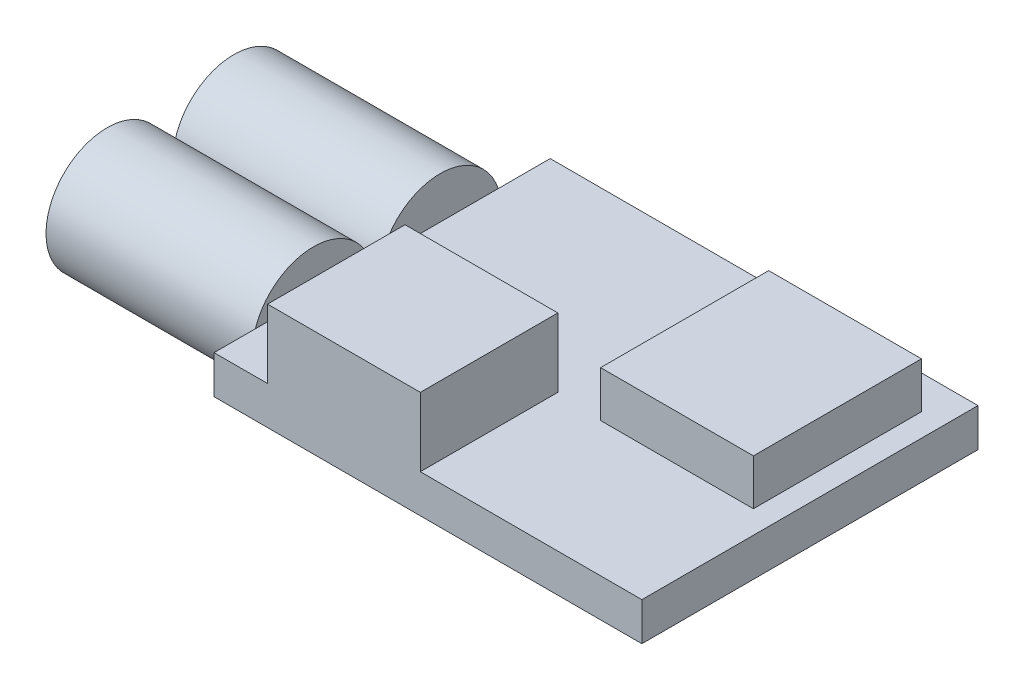
from build123d import *

# Parameters (mm, degrees)
SKETCH1_W           = 28
SKETCH1_H           = 22
BOSS_EXTRUDE1_DEPTH = 2.5
SKETCH2_W           = 10
SKETCH2_H           = 9
BOSS_EXTRUDE2_DEPTH = 4.5
SKETCH3_W           = 10
SKETCH3_H           = 11
BOSS_EXTRUDE3_DEPTH = 3
SKETCH4_R           = 4
BOSS_EXTRUDE4_DEPTH = 13.5


with BuildPart() as part:
    # Sketch1 → Boss-Extrude1 (new body)
    with BuildSketch(Plane(origin=(0, 0, 0), x_dir=(1, 0, 0), z_dir=(0, 1, 0))):
        Rectangle(SKETCH1_W, SKETCH1_H)
    extrude(amount=BOSS_EXTRUDE1_DEPTH)

    # Sketch2 → Boss-Extrude2 (add)
    with BuildSketch(Plane(origin=(0, 2.5, 0), x_dir=(1, 0, 0), z_dir=(0, 1, 0))):
        with Locations((-5.5, -6.5)):
            Rectangle(SKETCH2_W, SKETCH2_H)
    extrude(amount=BOSS_EXTRUDE2_DEPTH)

    # Sketch3 → Boss-Extrude3 (add)
    with BuildSketch(Plane(origin=(0, 2.5, 0), x_dir=(1, 0, 0), z_dir=(0, 1, 0))):
        with Locations((7.5, 3.3)):
            Rectangle(SKETCH3_W, SKETCH3_H)
    extrude(amount=BOSS_EXTRUDE3_DEPTH)

    # Sketch4 → Boss-Extrude4 (add)
    with BuildSketch(Plane.ZY.offset(14)):
        with Locations((-3.8, 1.25)):
            Circle(SKETCH4_R)
        with Locations((4.5, 1.25)):
            Circle(SKETCH4_R)
    extrude(amount=BOSS_EXTRUDE4_DEPTH)


solid = part.part
